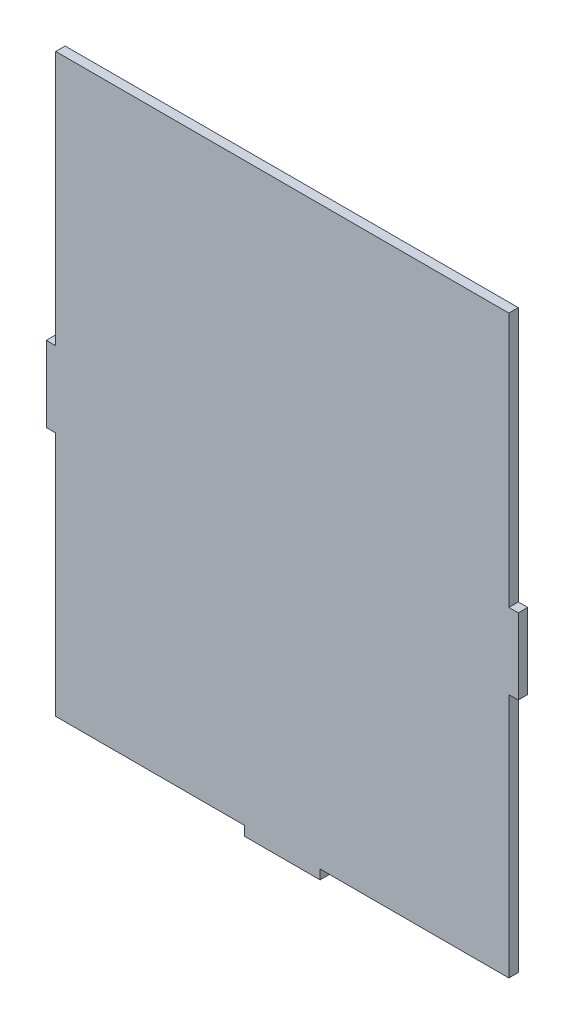
from build123d import *

# Parameters (mm, degrees)
BOSS_EXTRU_1_DEPTH = 5


with BuildPart() as part:
    # Esquisse1 → Boss.-Extru.1 (new body)
    with BuildSketch(Plane.XY):
        Polygon((5, 15), (245, 15), (245, -120), (250, -120), (250, -160), (245, -160), (245, -290), (145, -290), (145, -295), (105, -295), (105, -290), (5, -290), (5, -160), (0, -160), (0, -120), (5, -120), align=None)
    extrude(amount=BOSS_EXTRU_1_DEPTH)


solid = part.part
